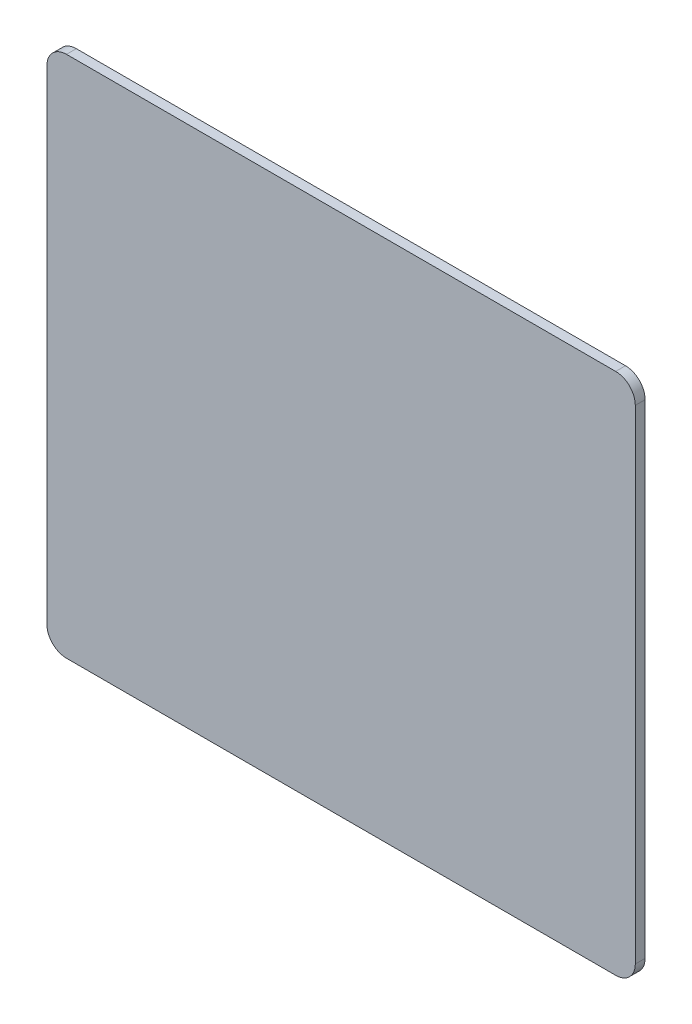
from build123d import *

# Parameters (mm, degrees)
EXTRUDE_1_DEPTH = 1.5


with BuildPart() as part:
    # 草图1 → 凸台-拉伸1 (new body)
    with BuildSketch(Plane.XY):
        with BuildLine():
            Line((42, -40), (-42, -40))
            ThreePointArc((-42, -40), (-44.121320344, -39.121320344), (-45, -37))
            Line((-45, -37), (-45, 37))
            ThreePointArc((-45, 37), (-44.121320344, 39.121320344), (-42, 40))
            Line((-42, 40), (42, 40))
            ThreePointArc((42, 40), (44.121320344, 39.121320344), (45, 37))
            Line((45, 37), (45, -37))
            ThreePointArc((45, -37), (44.121320344, -39.121320344), (42, -40))
        make_face()
    extrude(amount=EXTRUDE_1_DEPTH)


solid = part.part
